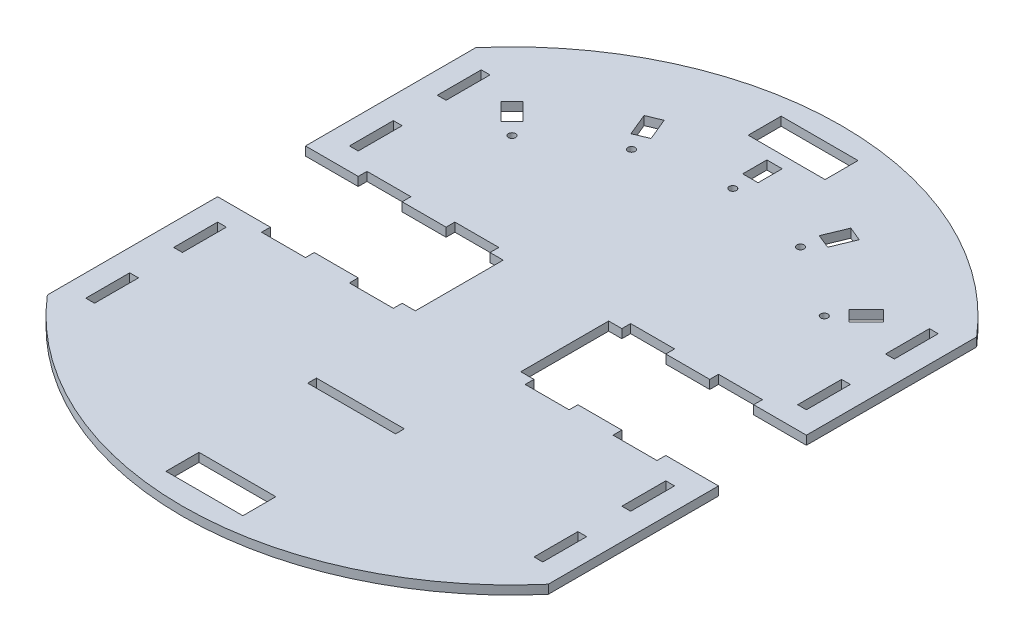
from build123d import *

# Parameters (mm, degrees)
SKICA1_W                = 35
SKICA1_H                = 15
SKICA1_W_2              = 40
SKICA1_H_2              = 4
SKICA1_R                = 1.625
SKICA1_W_3              = 7
SKICA1_H_3              = 11
SKICA1_W_4              = 4
SKICA1_H_4              = 20
P_IDAT_VYSUNUT_M1_DEPTH = 4


with BuildPart() as part:
    # Skica1 → Přidat vysunutím1 (new body)
    with BuildSketch(Plane(origin=(0, 0, 0), x_dir=(1, 0, 0), z_dir=(0, 1, 0))):
        with BuildLine():
            Line((-114, 97.488460856), (-114, 20))
            Line((-114, 20), (-90, 20))
            Line((-90, 20), (-90, 24))
            Line((-90, 24), (-70, 24))
            Line((-70, 24), (-70, 20))
            Line((-70, 20), (-50, 20))
            Line((-50, 20), (-50, 24))
            Line((-50, 24), (-30, 24))
            Line((-30, 24), (-30, 20))
            Line((-30, 20), (-24, 20))
            Line((-24, 20), (-24, -20))
            Line((-24, -20), (-30, -20))
            Line((-30, -20), (-30, -24))
            Line((-30, -24), (-50, -24))
            Line((-50, -24), (-50, -20))
            Line((-50, -20), (-70, -20))
            Line((-70, -20), (-70, -24))
            Line((-70, -24), (-90, -24))
            Line((-90, -24), (-90, -20))
            Line((-90, -20), (-114, -20))
            Line((-114, -20), (-114, -97.488460856))
            ThreePointArc((-114, -97.488460856), (0, -150), (114, -97.488460856))
            Line((114, -97.488460856), (114, -20))
            Line((114, -20), (90, -20))
            Line((90, -20), (90, -24))
            Line((90, -24), (70, -24))
            Line((70, -24), (70, -20))
            Line((70, -20), (50, -20))
            Line((50, -20), (50, -24))
            Line((50, -24), (30, -24))
            Line((30, -24), (30, -20))
            Line((30, -20), (24, -20))
            Line((24, -20), (24, 20))
            Line((24, 20), (30, 20))
            Line((30, 20), (30, 24))
            Line((30, 24), (50, 24))
            Line((50, 24), (50, 20))
            Line((50, 20), (70, 20))
            Line((70, 20), (70, 24))
            Line((70, 24), (90, 24))
            Line((90, 24), (90, 20))
            Line((90, 20), (114, 20))
            Line((114, 20), (114, 97.488460856))
            ThreePointArc((114, 97.488460856), (0, 150), (-114, 97.488460856))
        make_face()
        with Locations((0, -132.5)):
            Rectangle(SKICA1_W, SKICA1_H, mode=Mode.SUBTRACT)
        with Locations((0, -71)):
            Rectangle(SKICA1_W_2, SKICA1_H_2, mode=Mode.SUBTRACT)
        with Locations((0, 100.5)):
            Circle(SKICA1_R, mode=Mode.SUBTRACT)
        with Locations((0, 114)):
            Rectangle(SKICA1_W_3, SKICA1_H_3, mode=Mode.SUBTRACT)
        with Locations((0, 132.5)):
            Rectangle(SKICA1_W, SKICA1_H, mode=Mode.SUBTRACT)
        with Locations((-102, 40)):
            Rectangle(SKICA1_W_4, SKICA1_H_4, mode=Mode.SUBTRACT)
        with Locations((-71.064231509, 71.064231509)):
            Circle(SKICA1_R, mode=Mode.SUBTRACT)
        with Locations((-102, 80)):
            Rectangle(SKICA1_W_4, SKICA1_H_4, mode=Mode.SUBTRACT)
        Polygon((-86.974134086, 82.024386618), (-82.024386618, 86.974134086), (-74.246212025, 79.195959493), (-79.195959493, 74.246212025), align=None, mode=Mode.SUBTRACT)
        Polygon((-48.964248531, 109.064212122), (-42.497091804, 111.742996148), (-38.287574048, 101.580321291), (-44.754730775, 98.901537264), align=None, mode=Mode.SUBTRACT)
        with Locations((-38.459684953, 92.849893017)):
            Circle(SKICA1_R, mode=Mode.SUBTRACT)
        with Locations((-102, -40)):
            Rectangle(SKICA1_W_4, SKICA1_H_4, mode=Mode.SUBTRACT)
        with Locations((-102, -80)):
            Rectangle(SKICA1_W_4, SKICA1_H_4, mode=Mode.SUBTRACT)
        with Locations((102, 80)):
            Rectangle(SKICA1_W_4, SKICA1_H_4, mode=Mode.SUBTRACT)
        with Locations((71.064231509, 71.064231509)):
            Circle(SKICA1_R, mode=Mode.SUBTRACT)
        with Locations((102, 40)):
            Rectangle(SKICA1_W_4, SKICA1_H_4, mode=Mode.SUBTRACT)
        with Locations((38.459684953, 92.849893017)):
            Circle(SKICA1_R, mode=Mode.SUBTRACT)
        Polygon((82.024386618, 86.974134086), (86.974134086, 82.024386618), (79.195959493, 74.246212025), (74.246212025, 79.195959493), align=None, mode=Mode.SUBTRACT)
        Polygon((42.497091804, 111.742996148), (48.964248531, 109.064212122), (44.754730775, 98.901537264), (38.287574048, 101.580321291), align=None, mode=Mode.SUBTRACT)
        with Locations((102, -40)):
            Rectangle(SKICA1_W_4, SKICA1_H_4, mode=Mode.SUBTRACT)
        with Locations((102, -80)):
            Rectangle(SKICA1_W_4, SKICA1_H_4, mode=Mode.SUBTRACT)
    extrude(amount=P_IDAT_VYSUNUT_M1_DEPTH)


solid = part.part
